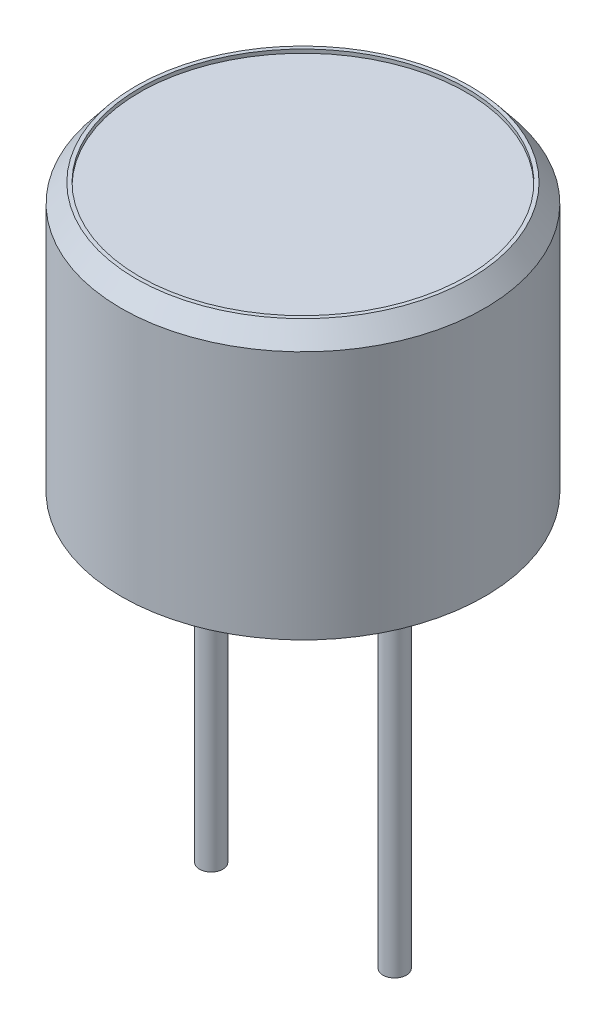
from build123d import *

# Parameters (mm, degrees)
SKETCH1_R           = 4.95
BOSS_EXTRUDE1_DEPTH = 7.3
CHAMFER1_SIZE       = 0.5
CHAMFER1_SIZE2      = 0.4
SKETCH2_R           = 0.32
BOSS_EXTRUDE2_DEPTH = 10
SKETCH3_R           = 4.45
CUT_EXTRUDE1_DEPTH  = 0.1


with BuildPart() as part:
    # Sketch1 → Boss-Extrude1 (new body)
    with BuildSketch(Plane(origin=(0, 0, 0), x_dir=(1, 0, 0), z_dir=(0, 1, 0))):
        Circle(SKETCH1_R)
    extrude(amount=BOSS_EXTRUDE1_DEPTH)

    # Chamfer1
    chamfer1_edges = [part.edges().sort_by_distance(p)[0] for p in [
        (-4.95, 7.3, 0),
    ]]
    chamfer1_side = [part.faces().sort_by_distance(p)[0] for p in [
        (-4.95, 3.65, 0),
    ]]
    chamfer(chamfer1_edges, length=CHAMFER1_SIZE, length2=CHAMFER1_SIZE2, reference=chamfer1_side[0])

    # Sketch2 → Boss-Extrude2 (add)
    with BuildSketch(Plane.XZ):
        with Locations((-2.5, 0)):
            Circle(SKETCH2_R)
        with Locations((2.5, 0)):
            Circle(SKETCH2_R)
    extrude(amount=BOSS_EXTRUDE2_DEPTH)

    # Sketch3 → Cut-Extrude1 (cut)
    with BuildSketch(Plane(origin=(0, 7.3, 0), x_dir=(1, 0, 0), z_dir=(0, 1, 0))):
        Circle(SKETCH3_R)
    extrude(amount=-CUT_EXTRUDE1_DEPTH, mode=Mode.SUBTRACT)


solid = part.part
